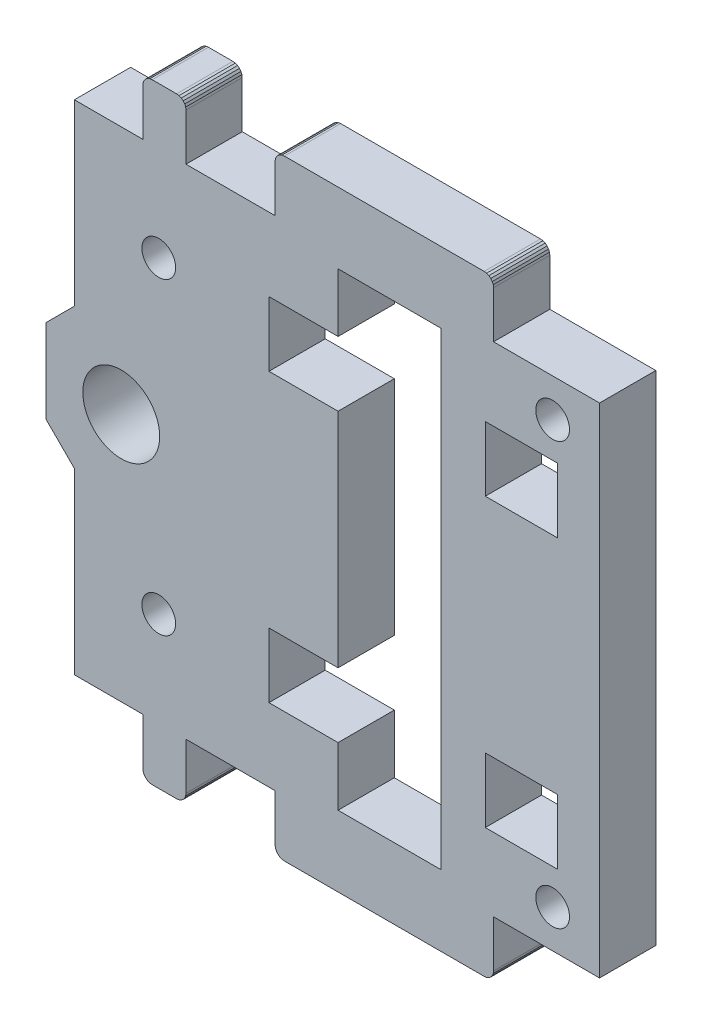
from build123d import *

# Parameters (mm, degrees)
MODEL_R                  = 1.8
MODEL_R_2                = 4.1
MODEL_W                  = 7.7
MODEL_H                  = 6.9
RESSALTO_EXTRUS_O1_DEPTH = 6


with BuildPart() as part:
    # Model → Ressalto-extrusão1 (new body)
    with BuildSketch(Plane.XY):
        Polygon((52.383398063, 73.075042987), (52.28349764, 72.833862032), (52.249423467, 72.575042987), (52.249423467, 67.575042987), (42.750846371, 67.575042987), (42.750846371, 72.575042987), (42.716772197, 72.833862032), (42.616871774, 73.075042987), (42.457953152, 73.282149768), (42.250846371, 73.441068391), (42.009665416, 73.540968814), (41.750846371, 73.575042987), (39.151153585, 73.575042987), (38.89233454, 73.540968814), (38.651153585, 73.441068391), (38.444046804, 73.282149768), (38.285128182, 73.075042987), (38.185227759, 72.833862032), (38.151153585, 72.575042987), (38.151153585, 67.575042987), (30.849423467, 67.575042987), (30.849423467, 48.514129082), (27.849423467, 45.514129082), (27.849423467, 41.05308967), (27.845731051, 41.025042987), (27.849423467, 40.996996305), (27.849423467, 36.535956893), (30.849423467, 33.535956893), (30.849423467, 14.475042987), (38.151153585, 14.475042987), (38.155087445, 9.474256339), (38.189331183, 9.215590795), (38.289324067, 8.974588885), (38.448258531, 8.767658139), (38.655314239, 8.608886505), (38.896394733, 8.509083236), (39.155087136, 8.475042987), (41.749423467, 8.475042987), (42.008242512, 8.509117161), (42.249423467, 8.609017584), (42.456530248, 8.767936206), (42.61544887, 8.975042987), (42.715349293, 9.216223942), (42.749423467, 9.475042987), (42.749423467, 14.475042987), (52.249423467, 14.475042987), (52.249423467, 9.475042987), (52.28349764, 9.216223942), (52.383398063, 8.975042987), (52.542316685, 8.767936206), (52.749423467, 8.609017584), (52.990604422, 8.509117161), (53.249423467, 8.475042987), (74.549423467, 8.475042987), (74.808242512, 8.509117161), (75.049423467, 8.609017584), (75.256530248, 8.767936206), (75.41544887, 8.975042987), (75.515349293, 9.216223942), (75.549423467, 9.475042987), (75.549423467, 14.475042987), (86.849423467, 14.475042987), (86.849423467, 67.575042987), (75.549423467, 67.575042987), (75.549423467, 72.575042987), (75.515349293, 72.833862032), (75.41544887, 73.075042987), (75.256530248, 73.282149768), (75.049423467, 73.441068391), (74.808242512, 73.540968814), (74.549423467, 73.575042987), (53.249423467, 73.575042987), (52.990604421, 73.540968814), (52.749423467, 73.441068391), (52.542316685, 73.282149768), align=None)
        with Locations((81.849423467, 18.525042987)):
            Circle(MODEL_R, mode=Mode.SUBTRACT)
        with Locations((39.849423467, 24.575042987)):
            Circle(MODEL_R, mode=Mode.SUBTRACT)
        with Locations((35.849423467, 41.025042987)):
            Circle(MODEL_R_2, mode=Mode.SUBTRACT)
        with Locations((39.849423467, 57.475042987)):
            Circle(MODEL_R, mode=Mode.SUBTRACT)
        with Locations((81.849423467, 63.525042987)):
            Circle(MODEL_R, mode=Mode.SUBTRACT)
        Polygon((58.966889554, 29.175042987), (58.966889554, 52.875042987), (51.598425396, 52.875042987), (51.598425396, 59.775042987), (58.966889554, 59.775042987), (58.966889554, 66.025032836), (69.966884557, 66.025032836), (69.966884557, 16.025053138), (58.966889554, 16.025053138), (58.966889554, 22.275042987), (51.598425396, 22.275042987), (51.598425396, 29.175042987), align=None, mode=Mode.SUBTRACT)
        with Locations((78.516884557, 56.325042987)):
            Rectangle(MODEL_W, MODEL_H, mode=Mode.SUBTRACT)
        with Locations((78.516884557, 25.725042987)):
            Rectangle(MODEL_W, MODEL_H, mode=Mode.SUBTRACT)
    extrude(amount=RESSALTO_EXTRUS_O1_DEPTH)


solid = part.part
